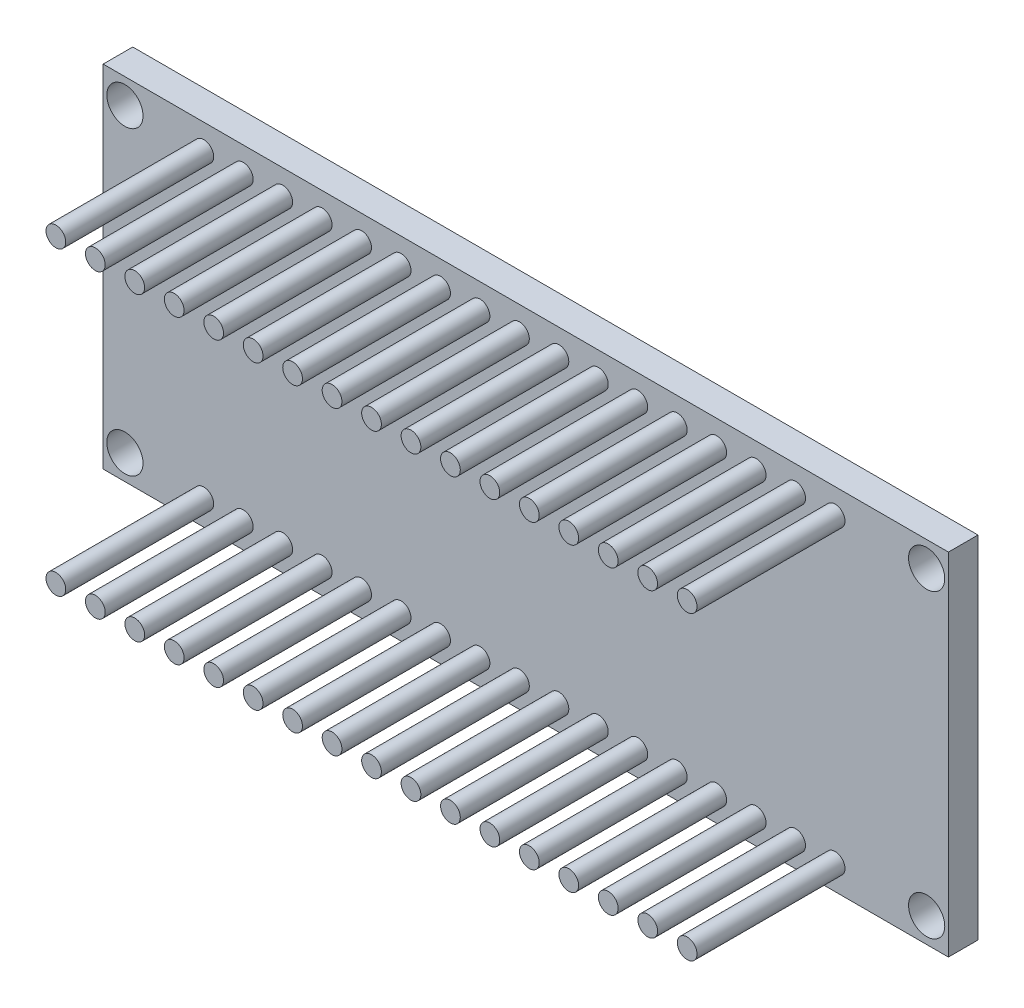
from build123d import *

# Parameters (mm, degrees)
SKETCH1_W           = 42.844819815
SKETCH1_H           = 17.78
SKETCH1_R           = 0.917394869
BOSS_EXTRUDE1_DEPTH = 1.5
SKETCH2_R           = 0.5
BOSS_EXTRUDE2_DEPTH = 7.5
SKETCH3_W           = 5
SKETCH3_H           = 7
BOSS_EXTRUDE3_DEPTH = 2
FILLET1_R           = 0.75


with BuildPart() as part:
    # Sketch1 → Boss-Extrude1 (new body)
    with BuildSketch(Plane.XY):
        with Locations((-197.662982249, 61.653534283)):
            Rectangle(SKETCH1_W, SKETCH1_H)
        with Locations((-217.982982248, 69.278534283)):
            Circle(SKETCH1_R, mode=Mode.SUBTRACT)
        with Locations((-217.982982248, 54.028534283)):
            Circle(SKETCH1_R, mode=Mode.SUBTRACT)
        with Locations((-177.342982248, 54.028534283)):
            Circle(SKETCH1_R, mode=Mode.SUBTRACT)
        with Locations((-177.342982248, 69.278534283)):
            Circle(SKETCH1_R, mode=Mode.SUBTRACT)
    extrude(amount=BOSS_EXTRUDE1_DEPTH)

    # Sketch2 → Boss-Extrude2 (add)
    with BuildSketch(Plane.XY.offset(1.5)):
        with Locations((-213.982982248, 69.278534283)):
            Circle(SKETCH2_R)
        with Locations((-213.982982248, 54.028534283)):
            Circle(SKETCH2_R)
        with Locations((-211.982982248, 69.278534283)):
            Circle(SKETCH2_R)
        with Locations((-211.982982248, 54.028534283)):
            Circle(SKETCH2_R)
        with Locations((-209.982982248, 69.278534283)):
            Circle(SKETCH2_R)
        with Locations((-209.982982248, 54.028534283)):
            Circle(SKETCH2_R)
        with Locations((-207.982982248, 69.278534283)):
            Circle(SKETCH2_R)
        with Locations((-207.982982248, 54.028534283)):
            Circle(SKETCH2_R)
        with Locations((-205.982982248, 69.278534283)):
            Circle(SKETCH2_R)
        with Locations((-205.982982248, 54.028534283)):
            Circle(SKETCH2_R)
        with Locations((-203.982982248, 69.278534283)):
            Circle(SKETCH2_R)
        with Locations((-203.982982248, 54.028534283)):
            Circle(SKETCH2_R)
        with Locations((-201.982982248, 69.278534283)):
            Circle(SKETCH2_R)
        with Locations((-201.982982248, 54.028534283)):
            Circle(SKETCH2_R)
        with Locations((-199.982982248, 69.278534283)):
            Circle(SKETCH2_R)
        with Locations((-199.982982248, 54.028534283)):
            Circle(SKETCH2_R)
        with Locations((-197.982982248, 69.278534283)):
            Circle(SKETCH2_R)
        with Locations((-197.982982248, 54.028534283)):
            Circle(SKETCH2_R)
        with Locations((-195.982982248, 69.278534283)):
            Circle(SKETCH2_R)
        with Locations((-195.982982248, 54.028534283)):
            Circle(SKETCH2_R)
        with Locations((-193.982982248, 69.278534283)):
            Circle(SKETCH2_R)
        with Locations((-193.982982248, 54.028534283)):
            Circle(SKETCH2_R)
        with Locations((-191.982982248, 69.278534283)):
            Circle(SKETCH2_R)
        with Locations((-191.982982248, 54.028534283)):
            Circle(SKETCH2_R)
        with Locations((-189.982982248, 69.278534283)):
            Circle(SKETCH2_R)
        with Locations((-189.982982248, 54.028534283)):
            Circle(SKETCH2_R)
        with Locations((-187.982982248, 69.278534283)):
            Circle(SKETCH2_R)
        with Locations((-187.982982248, 54.028534283)):
            Circle(SKETCH2_R)
        with Locations((-185.982982248, 69.278534283)):
            Circle(SKETCH2_R)
        with Locations((-185.982982248, 54.028534283)):
            Circle(SKETCH2_R)
        with Locations((-183.982982248, 69.278534283)):
            Circle(SKETCH2_R)
        with Locations((-183.982982248, 54.028534283)):
            Circle(SKETCH2_R)
        with Locations((-181.982982248, 69.278534283)):
            Circle(SKETCH2_R)
        with Locations((-181.982982248, 54.028534283)):
            Circle(SKETCH2_R)
    extrude(amount=BOSS_EXTRUDE2_DEPTH)

    # Sketch3 → Boss-Extrude3 (add)
    with BuildSketch(Plane(origin=(0, 0, 0), x_dir=(-1, 0, 0), z_dir=(0, 0, -1))):
        with Locations((217.835392156, 61.653534283)):
            Rectangle(SKETCH3_W, SKETCH3_H)
    extrude(amount=BOSS_EXTRUDE3_DEPTH)

    # Fillet1
    fillet1_edges = [part.edges().sort_by_distance(p)[0] for p in [
        (-219.710392156, 58.153534283, 0),
        (-219.710392156, 65.153534283, 0),
        (-217.835392156, 58.153534283, -2),
        (-217.835392156, 65.153534283, -2),
    ]]
    fillet(fillet1_edges, radius=FILLET1_R)


solid = part.part
